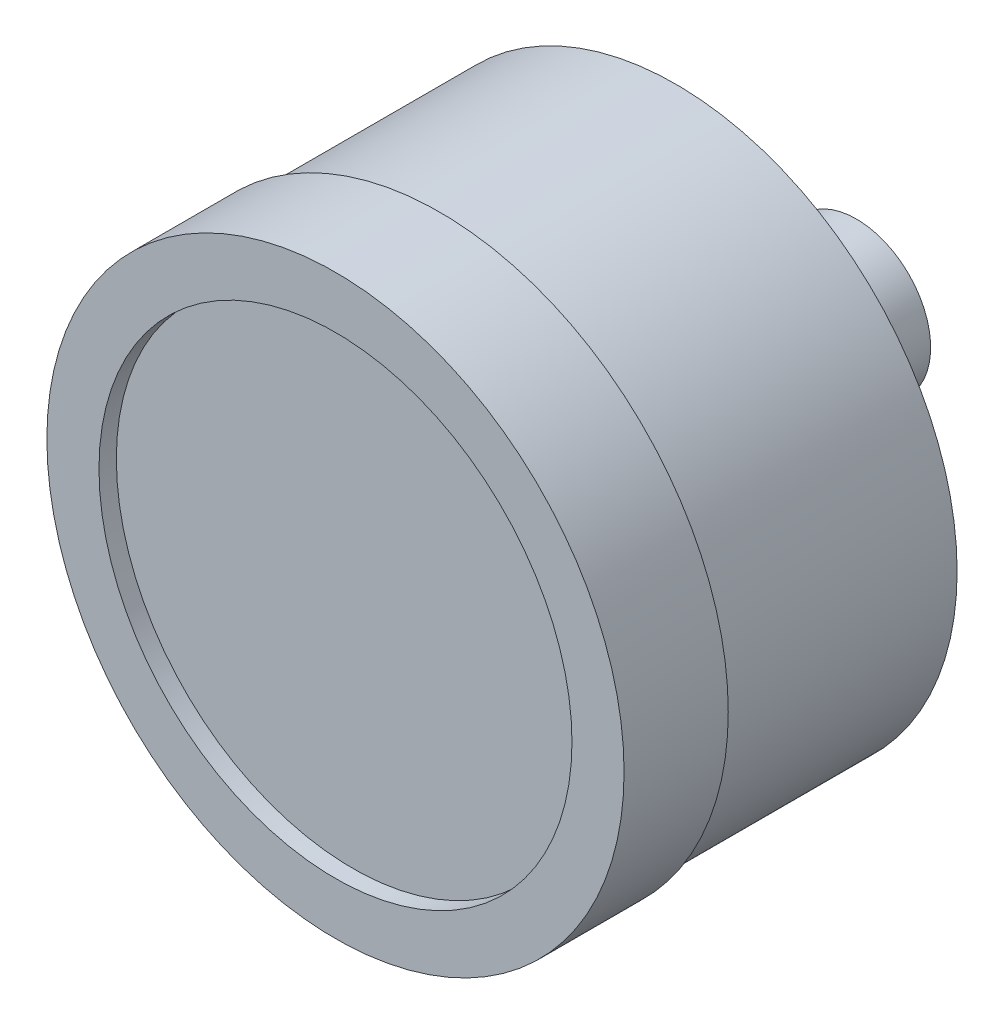
from build123d import *

# Parameters (mm, degrees)
SKETCH1_R           = 20.574
BOSS_EXTRUDE1_DEPTH = 24.892
SKETCH2_R           = 21.1074
BOSS_EXTRUDE2_DEPTH = 7.62
SKETCH3_R           = 17.2974
CUT_EXTRUDE1_DEPTH  = 1.27
SKETCH4_W           = 10.8585
SKETCH4_H           = 10.8585
BOSS_EXTRUDE3_DEPTH = 5.715
SKETCH5_R           = 5.42925
BOSS_EXTRUDE4_DEPTH = 7.493


with BuildPart() as part:
    # Sketch1 → Boss-Extrude1 (new body)
    with BuildSketch(Plane.XY):
        Circle(SKETCH1_R)
    extrude(amount=BOSS_EXTRUDE1_DEPTH)

    # Sketch2 → Boss-Extrude2 (add)
    with BuildSketch(Plane.XY.offset(24.892)):
        Circle(SKETCH2_R)
    extrude(amount=-BOSS_EXTRUDE2_DEPTH)

    # Sketch3 → Cut-Extrude1 (cut)
    with BuildSketch(Plane.XY.offset(24.892)):
        Circle(SKETCH3_R)
    extrude(amount=-CUT_EXTRUDE1_DEPTH, mode=Mode.SUBTRACT)

    # Sketch4 → Boss-Extrude3 (add)
    with BuildSketch(Plane(origin=(0, 0, 0), x_dir=(-1, 0, 0), z_dir=(0, 0, -1))):
        Rectangle(SKETCH4_W, SKETCH4_H)
    extrude(amount=BOSS_EXTRUDE3_DEPTH)

    # Sketch5 → Boss-Extrude4 (add)
    with BuildSketch(Plane(origin=(0, 0, -5.715), x_dir=(-1, 0, 0), z_dir=(0, 0, -1))):
        Circle(SKETCH5_R)
    extrude(amount=BOSS_EXTRUDE4_DEPTH)


solid = part.part
